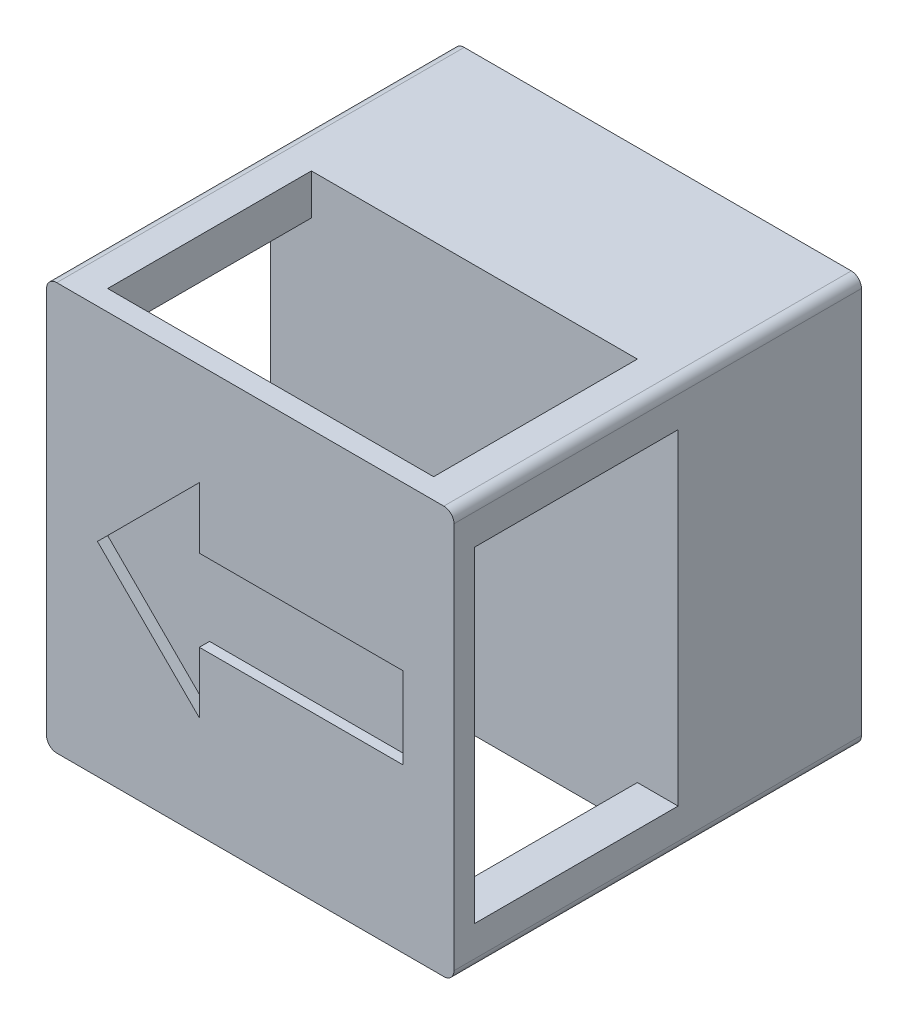
from build123d import *

# Parameters (mm, degrees)
SKETCH1_W           = 400
SKETCH1_H           = 400
BOSS_EXTRUDE1_DEPTH = 400
CUT_EXTRUDE1_DEPTH  = 200
CUT_EXTRUDE2_DEPTH  = 10
FILLET1_R           = 10


with BuildPart() as part:
    # Sketch1 → Boss-Extrude1 (new body)
    with BuildSketch(Plane.XY):
        Rectangle(SKETCH1_W, SKETCH1_H)
    extrude(amount=BOSS_EXTRUDE1_DEPTH)

    # Sketch2 → Cut-Extrude1 (cut)
    with BuildSketch(Plane.XY.offset(380)):
        Polygon((160, 200), (-160, 200), (-160, 160), (-200, 160), (-200, -160), (-160, -160), (-160, -200), (160, -200), (160, -160), (200, -160), (200, 160), (160, 160), align=None)
    extrude(amount=-CUT_EXTRUDE1_DEPTH, mode=Mode.SUBTRACT)

    # Sketch3 → Cut-Extrude2 (cut)
    with BuildSketch(Plane.XY.offset(400)):
        Polygon((-150, 0), (-50, 100), (-50, 40), (150, 40), (150, -40), (-50, -40), (-50, -100), align=None)
    extrude(amount=-CUT_EXTRUDE2_DEPTH, mode=Mode.SUBTRACT)

    # Fillet1
    fillet1_edges = [part.edges().sort_by_distance(p)[0] for p in [
        (200, -200, 200),
        (-200, -200, 200),
        (-200, 200, 200),
        (200, 200, 200),
    ]]
    fillet(fillet1_edges, radius=FILLET1_R)


solid = part.part
